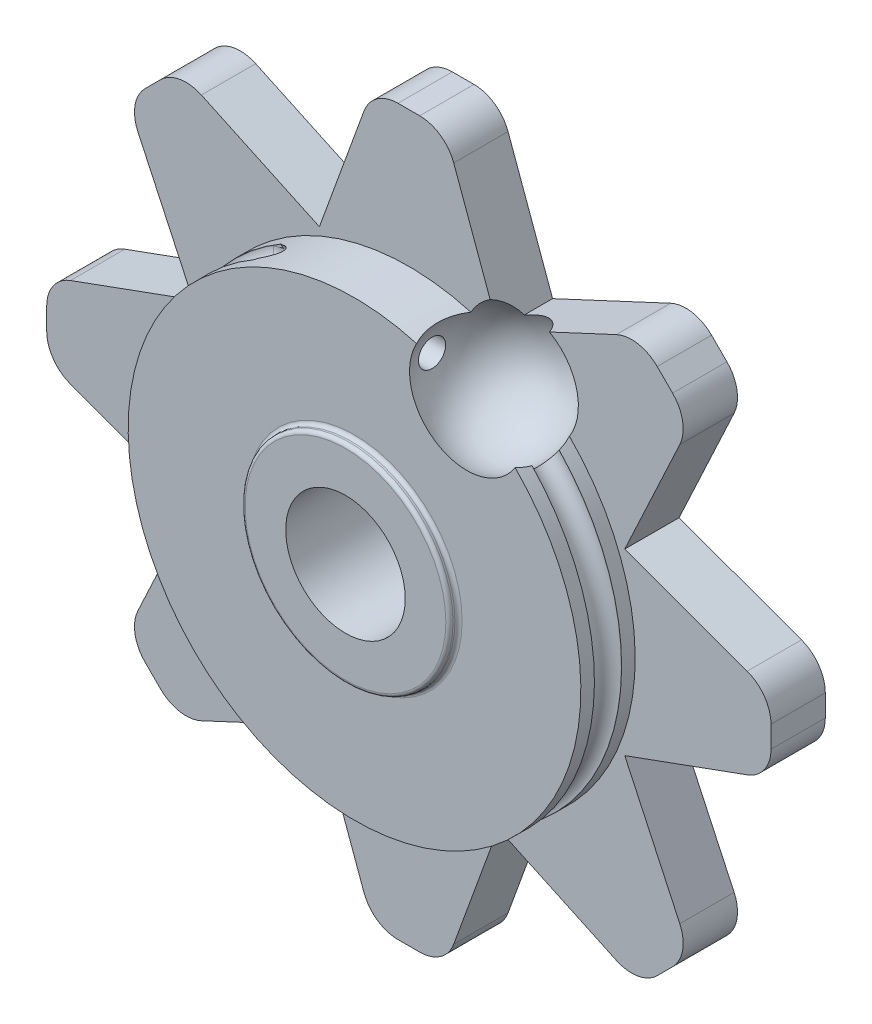
from build123d import *

# Parameters (mm, degrees)
SKETCH1_R                          = 6.25
BODY_DEPTH                         = 1.5
HOLE_TO_TRAP_CABLE_KNOT_DEPTH      = 10
HOLE_TO_TRAP_CABLE_KNOT_DEPTH_BACK = 9.965210539
SKETCH2_R                          = 0.375
THUMB_GRIP_DEPTH                   = 1.5
SKETCH13_R                         = 1.65
HOLE_FOR_SCREW_DEPTH               = 15.456832295
LIP_TO_CONTACT_HANDLE_DEPTH        = 0.25
LIP_TO_CONTACT_HANDLE_DEPTH_BACK   = 4.25
SKETCH21_R                         = 2.871579249
SKETCH21_R_2                       = 1.65
FILLET1_R                          = 0.1


with BuildPart() as part:
    # Sketch1 → body (new body)
    with BuildSketch(Plane.XY):
        Circle(SKETCH1_R)
    extrude(amount=BODY_DEPTH)

    # Sketch2 → Hole to trap cable knot (cut, two sides: drawn at the far end of the back side and taken through both)
    with BuildSketch(Plane(origin=(0, 0, 0), x_dir=(0, 0, -1), z_dir=(1, 0, 0)).offset(-HOLE_TO_TRAP_CABLE_KNOT_DEPTH_BACK)):
        with Locations((-0.75, 5.25)):
            Circle(SKETCH2_R)
        with Locations((-0.75, -4.75)):
            Circle(SKETCH2_R)
    extrude(amount=HOLE_TO_TRAP_CABLE_KNOT_DEPTH + HOLE_TO_TRAP_CABLE_KNOT_DEPTH_BACK, mode=Mode.SUBTRACT)

    # track for cable: sweep along a path in Sketch6
    with BuildLine(Plane.XY.offset(1.875)) as track_for_cable_path:
        ThreePointArc((-3.125, 5.412658774), (-0.078980905, -6.249500941), (3.260789939, 5.331955455))
    # Sketch10 → track for cable (sweep, cut)
    with BuildSketch(Plane(origin=(-5.412658774, 9.375, 0), x_dir=(-0.4999999999999889, 0.866025403784445, 0), z_dir=(-0.866025403784445, -0.4999999999999889, 0))):
        with BuildLine():
            Line((-4.583101682, -1.125), (-3.872701536, -1.125))
            Line((-3.872701536, -1.125), (-3.872701536, -0.374795087))
            Line((-3.872701536, -0.374795087), (-4.583101682, -0.374795087))
            ThreePointArc((-4.583101682, -0.374795087), (-4.958204138, -0.749897543), (-4.583101682, -1.125))
        make_face()
    sweep(path=track_for_cable_path.line, mode=Mode.SUBTRACT)

    # Sketch14 → thumb grip (add)
    with BuildSketch(Plane(origin=(0, 0, 0), x_dir=(-1, 0, 0), z_dir=(0, 0, -1))):
        with BuildLine():
            Line((5.729357486, 7.4822541), (2.469632038, 5.96221916))
            Line((2.469632038, 5.96221916), (1.239485083, 9.342020143))
            ThreePointArc((1.239485083, 9.342020143), (0.873368898, 9.819152044), (0.299792462, 10))
            Line((0.299792462, 10), (-0.299792462, 10))
            ThreePointArc((-0.299792462, 10), (-0.873368898, 9.819152044), (-1.239485083, 9.342020143))
            Line((-1.239485083, 9.342020143), (-2.469632038, 5.96221916))
            Line((-2.469632038, 5.96221916), (-5.729357486, 7.4822541))
            ThreePointArc((-5.729357486, 7.4822541), (-6.325623926, 7.560754066), (-6.859082529, 7.283053095))
            Line((-6.859082529, 7.283053095), (-7.283053095, 6.859082529))
            ThreePointArc((-7.283053095, 6.859082529), (-7.560754066, 6.325623926), (-7.4822541, 5.729357486))
            Line((-7.4822541, 5.729357486), (-5.96221916, 2.469632038))
            Line((-5.96221916, 2.469632038), (-9.342020143, 1.239485083))
            ThreePointArc((-9.342020143, 1.239485083), (-9.819152044, 0.873368898), (-10, 0.299792462))
            Line((-10, 0.299792462), (-10, -0.299792462))
            ThreePointArc((-10, -0.299792462), (-9.819152044, -0.873368898), (-9.342020143, -1.239485083))
            Line((-9.342020143, -1.239485083), (-5.96221916, -2.469632038))
            Line((-5.96221916, -2.469632038), (-7.4822541, -5.729357486))
            ThreePointArc((-7.4822541, -5.729357486), (-7.560754066, -6.325623926), (-7.283053095, -6.859082529))
            Line((-7.283053095, -6.859082529), (-6.859082529, -7.283053095))
            ThreePointArc((-6.859082529, -7.283053095), (-6.325623926, -7.560754066), (-5.729357486, -7.4822541))
            Line((-5.729357486, -7.4822541), (-2.469632038, -5.96221916))
            Line((-2.469632038, -5.96221916), (-1.239485083, -9.342020143))
            ThreePointArc((-1.239485083, -9.342020143), (-0.873368898, -9.819152044), (-0.299792462, -10))
            Line((-0.299792462, -10), (0.299792462, -10))
            ThreePointArc((0.299792462, -10), (0.873368898, -9.819152044), (1.239485083, -9.342020143))
            Line((1.239485083, -9.342020143), (2.469632038, -5.96221916))
            Line((2.469632038, -5.96221916), (5.729357486, -7.4822541))
            ThreePointArc((5.729357486, -7.4822541), (6.325623926, -7.560754066), (6.859082529, -7.283053095))
            Line((6.859082529, -7.283053095), (7.283053095, -6.859082529))
            ThreePointArc((7.283053095, -6.859082529), (7.560754066, -6.325623926), (7.4822541, -5.729357486))
            Line((7.4822541, -5.729357486), (5.96221916, -2.469632038))
            Line((5.96221916, -2.469632038), (9.342020143, -1.239485083))
            ThreePointArc((9.342020143, -1.239485083), (9.819152044, -0.873368898), (10, -0.299792462))
            Line((10, -0.299792462), (10, 0.299792462))
            ThreePointArc((10, 0.299792462), (9.819152044, 0.873368898), (9.342020143, 1.239485083))
            Line((9.342020143, 1.239485083), (5.96221916, 2.469632038))
            Line((5.96221916, 2.469632038), (7.4822541, 5.729357486))
            ThreePointArc((7.4822541, 5.729357486), (7.560754066, 6.325623926), (7.283053095, 6.859082529))
            Line((7.283053095, 6.859082529), (6.859082529, 7.283053095))
            ThreePointArc((6.859082529, 7.283053095), (6.325623926, 7.560754066), (5.729357486, 7.4822541))
        make_face()
    extrude(amount=THUMB_GRIP_DEPTH)

    # Sketch13 → hole for screw (cut, through all)
    with BuildSketch(Plane.XY.offset(1.5)):
        Circle(SKETCH13_R)
    extrude(amount=-HOLE_FOR_SCREW_DEPTH, mode=Mode.SUBTRACT)

    # Sketch20 → trap for ball (revolve, cut)
    with BuildSketch(Plane(origin=(3.1, 0, 0), x_dir=(0, 0, -1), z_dir=(1, 0, 0))):
        with BuildLine():
            Line((-0.75, 7), (-0.75, 3.5))
            ThreePointArc((-0.75, 3.5), (1, 5.25), (-0.75, 7))
        make_face()
    revolve(axis=Axis((3.1, 7.793428849, 0.75), (0, -1, 0)), mode=Mode.SUBTRACT)

    # Sketch21 → lip to contact handle (add, two sides: drawn at the far end of the back side and taken through both)
    with BuildSketch(Plane.XY.offset(1.5).offset(-LIP_TO_CONTACT_HANDLE_DEPTH_BACK)):
        Circle(SKETCH21_R)
        Circle(SKETCH21_R_2, mode=Mode.SUBTRACT)
    extrude(amount=LIP_TO_CONTACT_HANDLE_DEPTH + LIP_TO_CONTACT_HANDLE_DEPTH_BACK)

    # Fillet1
    fillet1_edges = [part.edges().sort_by_distance(p)[0] for p in [
        (-2.871579249, 0, 1.5),
        (-2.871579249, 0, 1.75),
        (-2.871579249, 0, -1.5),
        (-2.871579249, 0, -2.75),
    ]]
    fillet(fillet1_edges, radius=FILLET1_R)


solid = part.part
